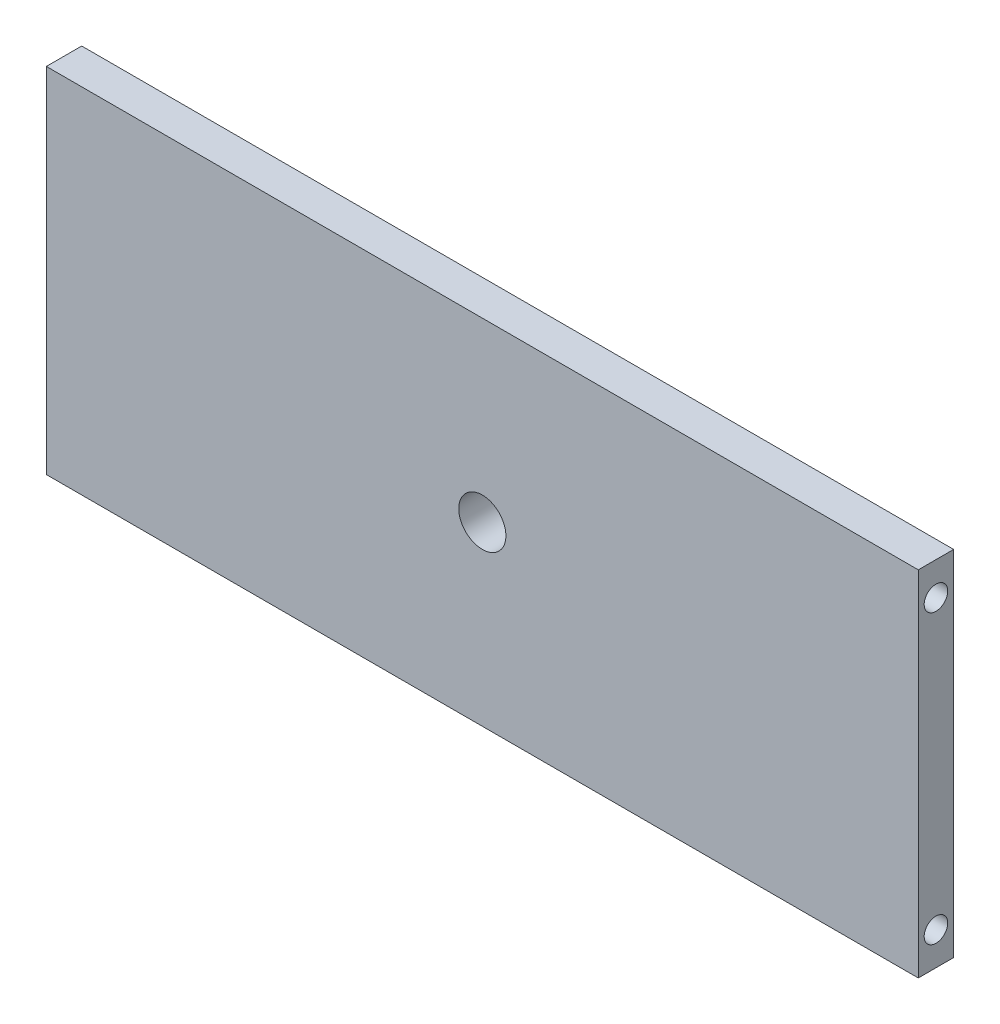
from build123d import *

# Parameters (mm, degrees)
SKETCH1_W           = 370
SKETCH1_H           = 150
BOSS_EXTRUDE1_DEPTH = 15
SKETCH2_R           = 5
CUT_EXTRUDE1_DEPTH  = 30
SKETCH3_R           = 5
CUT_EXTRUDE2_DEPTH  = 30
SKETCH4_R           = 10
CUT_EXTRUDE3_DEPTH  = 16


with BuildPart() as part:
    # Sketch1 → Boss-Extrude1 (new body)
    with BuildSketch(Plane.XY):
        Rectangle(SKETCH1_W, SKETCH1_H)
    extrude(amount=BOSS_EXTRUDE1_DEPTH)

    # Sketch2 → Cut-Extrude1 (cut)
    with BuildSketch(Plane.ZY.offset(185)):
        with Locations((7.5, 61)):
            Circle(SKETCH2_R)
        with Locations((7.5, -61)):
            Circle(SKETCH2_R)
    extrude(amount=-CUT_EXTRUDE1_DEPTH, mode=Mode.SUBTRACT)

    # Sketch3 → Cut-Extrude2 (cut)
    with BuildSketch(Plane(origin=(185, 0, 0), x_dir=(0, 0, -1), z_dir=(1, 0, 0))):
        with Locations((-7.5, 61)):
            Circle(SKETCH3_R)
        with Locations((-7.5, -61)):
            Circle(SKETCH3_R)
    extrude(amount=-CUT_EXTRUDE2_DEPTH, mode=Mode.SUBTRACT)

    # Sketch4 → Cut-Extrude3 (cut, through all)
    with BuildSketch(Plane.XY.offset(15)):
        Circle(SKETCH4_R)
    extrude(amount=-CUT_EXTRUDE3_DEPTH, mode=Mode.SUBTRACT)


solid = part.part
